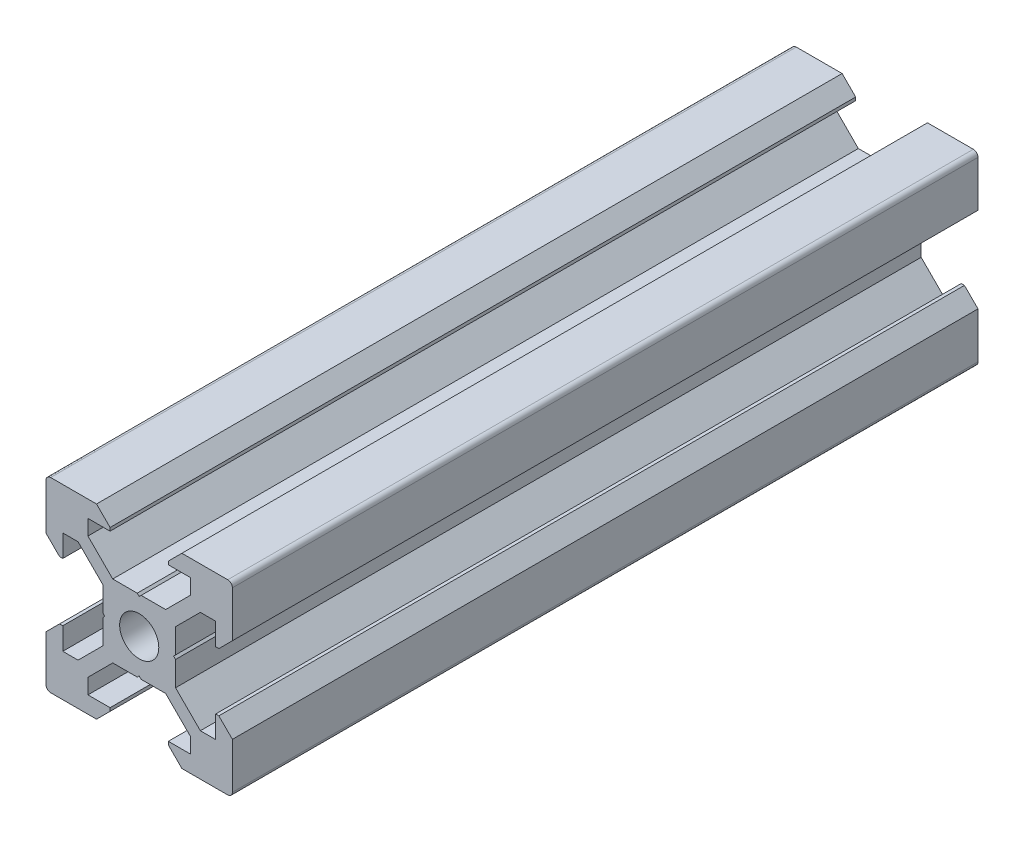
from build123d import *

# Parameters (mm, degrees)
SKETCH1_R           = 2.1
BOSS_EXTRUDE1_DEPTH = 80


with BuildPart() as part:
    # Sketch1 → Boss-Extrude1 (new body)
    with BuildSketch(Plane.XY):
        with BuildLine():
            Line((4.58, -10), (9.5, -10))
            ThreePointArc((9.5, -10), (9.853553391, -9.853553391), (10, -9.5))
            Line((10, -9.5), (10, -4.58))
            Line((10, -4.58), (8.545, -3.125))
            Line((8.545, -3.125), (8.2, -3.125))
            Line((8.2, -3.125), (8.2, -5.5))
            Line((8.2, -5.5), (6.560660172, -5.5))
            Line((6.560660172, -5.5), (3.9, -2.839339828))
            Line((3.9, -2.839339828), (3.9, -0.21))
            Line((3.9, -0.21), (3.69, 0))
            Line((3.69, 0), (3.9, 0.21))
            Line((3.9, 0.21), (3.9, 2.839339828))
            Line((3.9, 2.839339828), (6.560660172, 5.5))
            Line((6.560660172, 5.5), (8.2, 5.5))
            Line((8.2, 5.5), (8.2, 3.125))
            Line((8.2, 3.125), (8.545, 3.125))
            Line((8.545, 3.125), (10, 4.58))
            Line((10, 4.58), (10, 9.5))
            ThreePointArc((10, 9.5), (9.853553391, 9.853553391), (9.5, 10))
            Line((9.5, 10), (4.58, 10))
            Line((4.58, 10), (3.125, 8.545))
            Line((3.125, 8.545), (3.125, 8.2))
            Line((3.125, 8.2), (5.5, 8.2))
            Line((5.5, 8.2), (5.5, 6.560660172))
            Line((5.5, 6.560660172), (2.839339828, 3.9))
            Line((2.839339828, 3.9), (0.21, 3.9))
            Line((0.21, 3.9), (0, 3.69))
            Line((0, 3.69), (-0.21, 3.9))
            Line((-0.21, 3.9), (-2.839339828, 3.9))
            Line((-2.839339828, 3.9), (-5.5, 6.560660172))
            Line((-5.5, 6.560660172), (-5.5, 8.2))
            Line((-5.5, 8.2), (-3.125, 8.2))
            Line((-3.125, 8.2), (-3.125, 8.545))
            Line((-3.125, 8.545), (-4.58, 10))
            Line((-4.58, 10), (-9.5, 10))
            ThreePointArc((-9.5, 10), (-9.853553391, 9.853553391), (-10, 9.5))
            Line((-10, 9.5), (-10, 4.58))
            Line((-10, 4.58), (-8.545, 3.125))
            Line((-8.545, 3.125), (-8.2, 3.125))
            Line((-8.2, 3.125), (-8.2, 5.5))
            Line((-8.2, 5.5), (-6.560660172, 5.5))
            Line((-6.560660172, 5.5), (-3.9, 2.839339828))
            Line((-3.9, 2.839339828), (-3.9, 0.21))
            Line((-3.9, 0.21), (-3.69, 0))
            Line((-3.69, 0), (-3.9, -0.21))
            Line((-3.9, -0.21), (-3.9, -2.839339828))
            Line((-3.9, -2.839339828), (-6.560660172, -5.5))
            Line((-6.560660172, -5.5), (-8.2, -5.5))
            Line((-8.2, -5.5), (-8.2, -3.125))
            Line((-8.2, -3.125), (-8.545, -3.125))
            Line((-8.545, -3.125), (-10, -4.58))
            Line((-10, -4.58), (-10, -9.5))
            ThreePointArc((-10, -9.5), (-9.853553391, -9.853553391), (-9.5, -10))
            Line((-9.5, -10), (-4.58, -10))
            Line((-4.58, -10), (-3.125, -8.545))
            Line((-3.125, -8.545), (-3.125, -8.2))
            Line((-3.125, -8.2), (-5.5, -8.2))
            Line((-5.5, -8.2), (-5.5, -6.560660172))
            Line((-5.5, -6.560660172), (-2.839339828, -3.9))
            Line((-2.839339828, -3.9), (-0.21, -3.9))
            Line((-0.21, -3.9), (0, -3.69))
            Line((0, -3.69), (0.21, -3.9))
            Line((0.21, -3.9), (2.839339828, -3.9))
            Line((2.839339828, -3.9), (5.5, -6.560660172))
            Line((5.5, -6.560660172), (5.5, -8.2))
            Line((5.5, -8.2), (3.125, -8.2))
            Line((3.125, -8.2), (3.125, -8.545))
            Line((3.125, -8.545), (4.58, -10))
        make_face()
        Circle(SKETCH1_R, mode=Mode.SUBTRACT)
    extrude(amount=BOSS_EXTRUDE1_DEPTH)


solid = part.part
